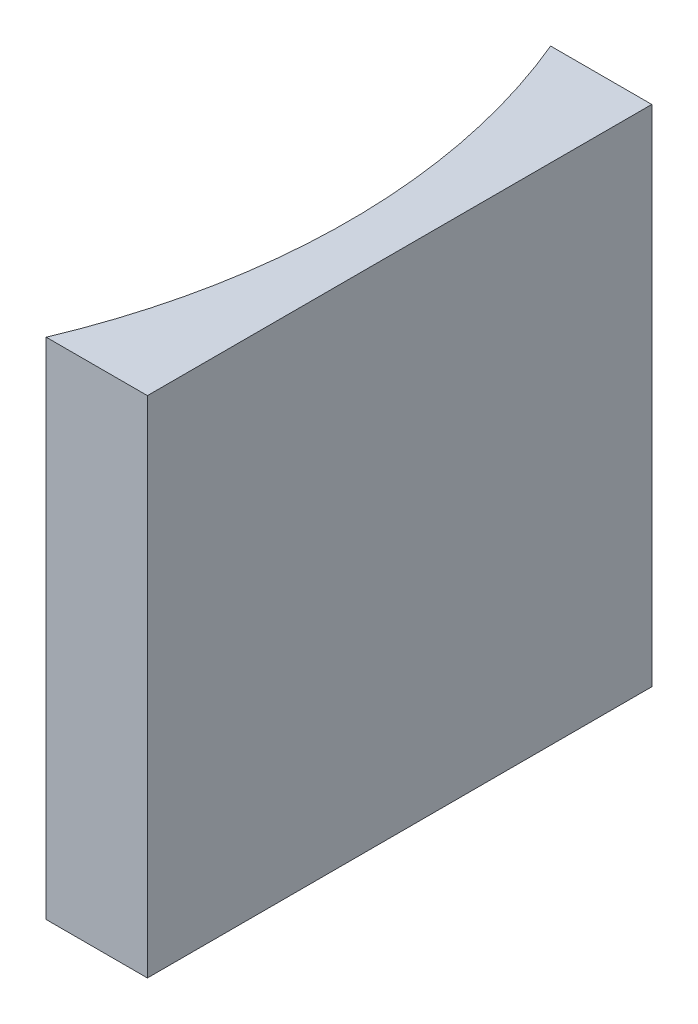
from build123d import *

# Parameters (mm, degrees)
EXTRUDE_1_DEPTH = 20


with BuildPart() as part:
    # 草图1 → 凸台-拉伸1 (new body)
    with BuildSketch(Plane(origin=(0, 0, 0), x_dir=(1, 0, 0), z_dir=(0, 1, 0))):
        with BuildLine():
            Line((0, 0), (0, -20))
            Line((0, -20), (-4.012581935, -20))
            ThreePointArc((-4.012581935, -20), (-2, -10), (-4.012581935, 0))
            Line((-4.012581935, 0), (0, 0))
        make_face()
    extrude(amount=EXTRUDE_1_DEPTH)


solid = part.part
